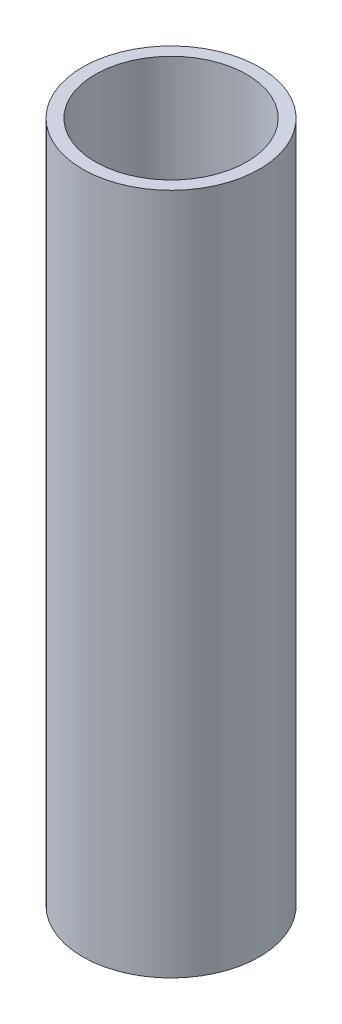
from build123d import *

# Parameters (mm, degrees)
SKETCH1_R           = 44.45
SKETCH1_R_2         = 38.1
BOSS_EXTRUDE1_DEPTH = 342.9


with BuildPart() as part:
    # Sketch1 → Boss-Extrude1 (new body)
    with BuildSketch(Plane(origin=(0, 0, 0), x_dir=(1, 0, 0), z_dir=(0, 1, 0))):
        Circle(SKETCH1_R)
        Circle(SKETCH1_R_2, mode=Mode.SUBTRACT)
    extrude(amount=BOSS_EXTRUDE1_DEPTH)


solid = part.part
